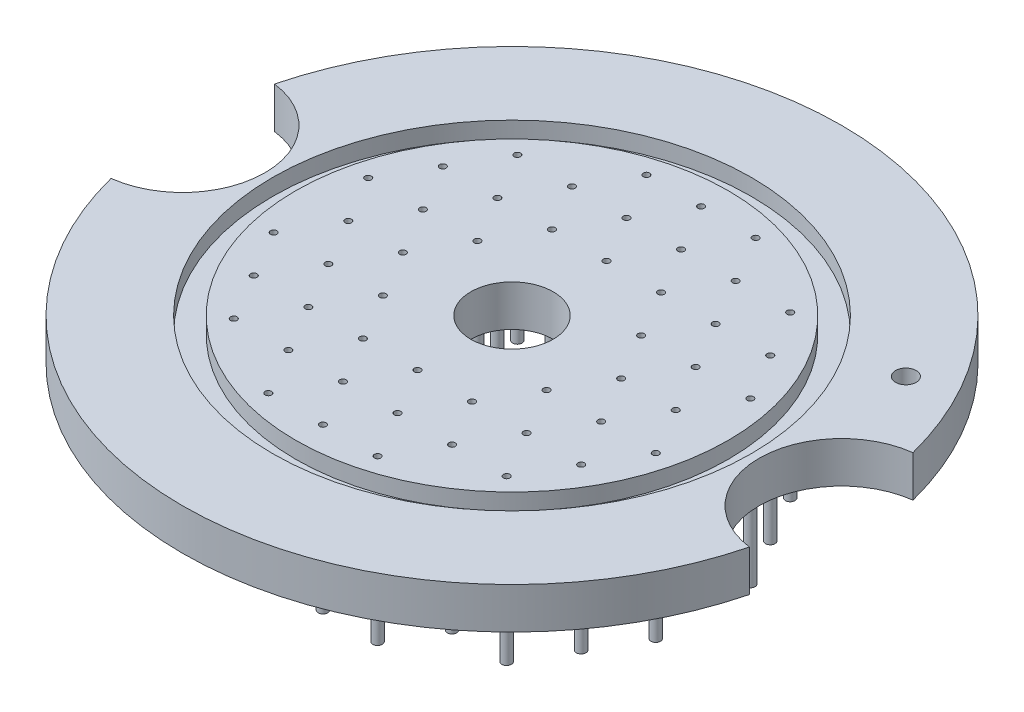
from build123d import *

# Parameters (mm, degrees)
F_1_2_0_5_DIAMETER_HOLE1_D   = 12.7
F_1_1_DIAMETER_HOLE1_D       = 25.4
F_1_8_0_125_DIAMETER_HOLE1_D = 3.175
SKETCH9_R                    = 0.7366
SKETCH9_R_2                  = 0.4953
BOSS_EXTRUDE1_DEPTH          = 18.415
SKETCH9_2_R                  = 0.4953
CUT_EXTRUDE1_DEPTH           = 74.086403532
CIRPATTERN4_COUNT            = 6


with BuildPart() as part:
    # Sketch1 → Revolve1 (revolve)
    with BuildSketch(Plane.XY):
        Polygon((-33.3375, 6.35), (-33.3375, 3.81), (-36.8935, 3.81), (-36.8935, 6.35), (-50.8, 6.35), (-50.8, 0), (0, 0), (0, 6.35), align=None)
    revolve(axis=Axis((0, 0, 0), (0, 1, 0)))

    # 1_2 _0.5_ Diameter Hole1 (through all)
    with Locations(Plane(origin=(0, 6.35, 0), x_dir=(1, 0, 0), z_dir=(0, 1, 0))):
        with Locations((0, 0)):
            Hole(F_1_2_0_5_DIAMETER_HOLE1_D / 2)

    # 1 _1_ Diameter Hole1 (through all)
    with Locations(Plane(origin=(0, 6.35, 0), x_dir=(1, 0, 0), z_dir=(0, 1, 0))):
        with Locations((50.8, 0), (-50.8, 0)):
            Hole(F_1_1_DIAMETER_HOLE1_D / 2)

    # 1_8 _0.125_ Diameter Hole1 (through all)
    with Locations(Plane(origin=(0, 6.35, 0), x_dir=(1, 0, 0), z_dir=(0, 1, 0))):
        with Locations((38.494829198, 22.225)):
            Hole(F_1_8_0_125_DIAMETER_HOLE1_D / 2)

    # Sketch9 → Boss-Extrude1 (add)
    # profile 1 of 8: a face of its own
    with BuildSketch(Plane.XZ):
        with Locations((8.41375, 29.146084964)):
            Circle(SKETCH9_R)
        with Locations((8.41375, 29.146084964)):
            Circle(SKETCH9_R_2, mode=Mode.SUBTRACT)
    # profile 2 of 8: a face of its own
    with BuildSketch(Plane.XZ):
        with Locations((0, 29.146084964)):
            Circle(SKETCH9_R)
        with Locations((0, 29.146084964)):
            Circle(SKETCH9_R_2, mode=Mode.SUBTRACT)
    # profile 3 of 8: a face of its own
    with BuildSketch(Plane.XZ):
        with Locations((4.206875, 21.859563723)):
            Circle(SKETCH9_R)
        with Locations((4.206875, 21.859563723)):
            Circle(SKETCH9_R_2, mode=Mode.SUBTRACT)
    # profile 4 of 8: a face of its own
    with BuildSketch(Plane.XZ):
        with Locations((0, 14.573042482)):
            Circle(SKETCH9_R)
        with Locations((0, 14.573042482)):
            Circle(SKETCH9_R_2, mode=Mode.SUBTRACT)
    # profile 5 of 8: a face of its own
    with BuildSketch(Plane.XZ):
        with Locations((-8.41375, 14.573042482)):
            Circle(SKETCH9_R)
        with Locations((-8.41375, 14.573042482)):
            Circle(SKETCH9_R_2, mode=Mode.SUBTRACT)
    # profile 6 of 8: a face of its own
    with BuildSketch(Plane.XZ):
        with Locations((-12.620625, 21.859563723)):
            Circle(SKETCH9_R)
        with Locations((-12.620625, 21.859563723)):
            Circle(SKETCH9_R_2, mode=Mode.SUBTRACT)
    # profile 7 of 8: a face of its own
    with BuildSketch(Plane.XZ):
        with Locations((-8.41375, 29.146084964)):
            Circle(SKETCH9_R)
        with Locations((-8.41375, 29.146084964)):
            Circle(SKETCH9_R_2, mode=Mode.SUBTRACT)
    # profile 8 of 8: a face of its own
    with BuildSketch(Plane.XZ):
        with Locations((-4.206875, 21.859563723)):
            Circle(SKETCH9_R)
        with Locations((-4.206875, 21.859563723)):
            Circle(SKETCH9_R_2, mode=Mode.SUBTRACT)
    boss_extrude1 = extrude(amount=BOSS_EXTRUDE1_DEPTH)

    # Sketch9_2 → Cut-Extrude1 (cut, through all)
    with BuildSketch(Plane.XZ):
        with Locations((8.41375, 29.146084964)):
            Circle(SKETCH9_2_R)
        with Locations((0, 29.146084964)):
            Circle(SKETCH9_2_R)
        with Locations((4.206875, 21.859563723)):
            Circle(SKETCH9_2_R)
        with Locations((0, 14.573042482)):
            Circle(SKETCH9_2_R)
        with Locations((-8.41375, 14.573042482)):
            Circle(SKETCH9_2_R)
        with Locations((-12.620625, 21.859563723)):
            Circle(SKETCH9_2_R)
        with Locations((-8.41375, 29.146084964)):
            Circle(SKETCH9_2_R)
        with Locations((-4.206875, 21.859563723)):
            Circle(SKETCH9_2_R)
    cut_extrude1 = extrude(amount=-CUT_EXTRUDE1_DEPTH, mode=Mode.SUBTRACT)

    # CirPattern4: Boss-Extrude1, Cut-Extrude1 ×6 about axis
    cirpattern4_axis = Axis((0, 7.5565, 0), (0, -1, 0))
    add([boss_extrude1.rotate(cirpattern4_axis, i * 360 / CIRPATTERN4_COUNT) for i in range(1, CIRPATTERN4_COUNT)])
    add([cut_extrude1.rotate(cirpattern4_axis, i * 360 / CIRPATTERN4_COUNT) for i in range(1, CIRPATTERN4_COUNT)], mode=Mode.SUBTRACT)


solid = part.part
